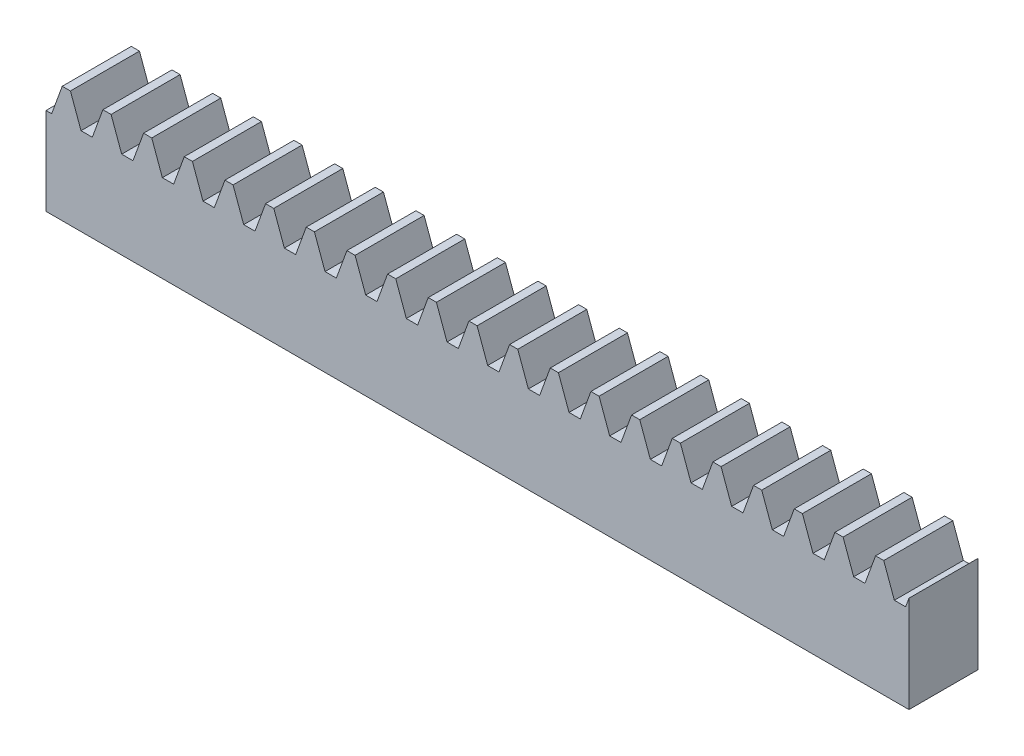
from build123d import *

# Parameters (mm, degrees)
BLANKSKE_W        = 100
BLANKSKE_H        = 13.5
BLANK_DEPTH       = 8
TOOTHCUTSIM_DEPTH = 102.223762032
TEETHCUTS_COUNT   = 22
TEETHCUTS_PITCH   = 4.712388975


with BuildPart() as part:
    # BlankSke → Blank (new body)
    with BuildSketch(Plane.XY):
        with Locations((50, 6.75)):
            Rectangle(BLANKSKE_W, BLANKSKE_H)
    extrude(amount=-BLANK_DEPTH)

    # TooCutSkeSim → ToothCutSim (cut, through all)
    with BuildSketch(Plane.XY):
        Polygon((0.654653055, 10.125), (-0.654653055, 10.125), (-1.892297439, 13.5254), (1.892297439, 13.5254), align=None)
    toothcutsim = extrude(amount=-TOOTHCUTSIM_DEPTH, mode=Mode.SUBTRACT)

    # TeethCuts: ToothCutSim ×22
    with Locations(*[(i * TEETHCUTS_PITCH, 0, 0) for i in range(1, TEETHCUTS_COUNT)]):
        add(toothcutsim, mode=Mode.SUBTRACT)


solid = part.part
